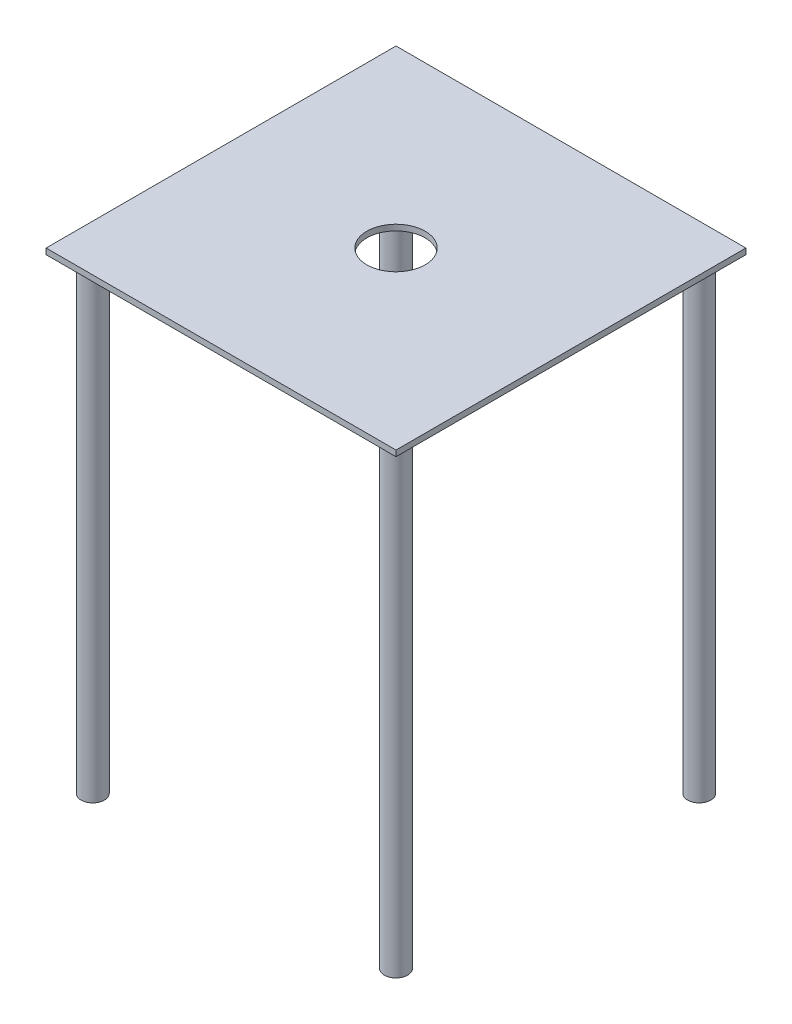
from build123d import *

# Parameters (mm, degrees)
SKETCH1_W        = 381
SKETCH1_H        = 381
EXTRUDE1_DEPTH   = 6.35
SKETCH2_R        = 31.75
EXTRUDE2_DEPTH   = 7.35
SKETCH3_R        = 12.7
EXTRUDE3_DEPTH   = 508
EXTRUDE3_2_DEPTH = 508
EXTRUDE3_3_DEPTH = 508
EXTRUDE3_4_DEPTH = 508


with BuildPart() as part:
    # Sketch1 → Extrude1 (new body)
    with BuildSketch(Plane(origin=(0, 0, 0), x_dir=(1, 0, 0), z_dir=(0, 1, 0))):
        Rectangle(SKETCH1_W, SKETCH1_H)
    extrude(amount=EXTRUDE1_DEPTH)

    # Sketch2 → Extrude2 (cut, through all)
    with BuildSketch(Plane(origin=(0, 6.35, 0), x_dir=(-1, 0, 0), z_dir=(0, 1, 0))):
        Circle(SKETCH2_R)
    extrude(amount=-EXTRUDE2_DEPTH, mode=Mode.SUBTRACT)


with BuildPart() as body_2:
    # Sketch3 → Extrude3 (new body)
    with BuildSketch(Plane(origin=(0, 0, 0), x_dir=(1, 0, 0), z_dir=(0, 1, 0))):
        with Locations((165.1, 165.1)):
            Circle(SKETCH3_R)
    extrude(amount=-EXTRUDE3_DEPTH)


with BuildPart() as body_3:
    # Sketch3 → Extrude3 2 (new body)
    with BuildSketch(Plane(origin=(0, 0, 0), x_dir=(1, 0, 0), z_dir=(0, 1, 0))):
        with Locations((-165.1, 165.1)):
            Circle(SKETCH3_R)
    extrude(amount=-EXTRUDE3_2_DEPTH)


with BuildPart() as body_4:
    # Sketch3 → Extrude3 3 (new body)
    with BuildSketch(Plane(origin=(0, 0, 0), x_dir=(1, 0, 0), z_dir=(0, 1, 0))):
        with Locations((165.1, -165.1)):
            Circle(SKETCH3_R)
    extrude(amount=-EXTRUDE3_3_DEPTH)


with BuildPart() as body_5:
    # Sketch3 → Extrude3 4 (new body)
    with BuildSketch(Plane(origin=(0, 0, 0), x_dir=(1, 0, 0), z_dir=(0, 1, 0))):
        with Locations((-165.1, -165.1)):
            Circle(SKETCH3_R)
    extrude(amount=-EXTRUDE3_4_DEPTH)


solid = Compound([part.part, body_2.part, body_3.part, body_4.part, body_5.part])
